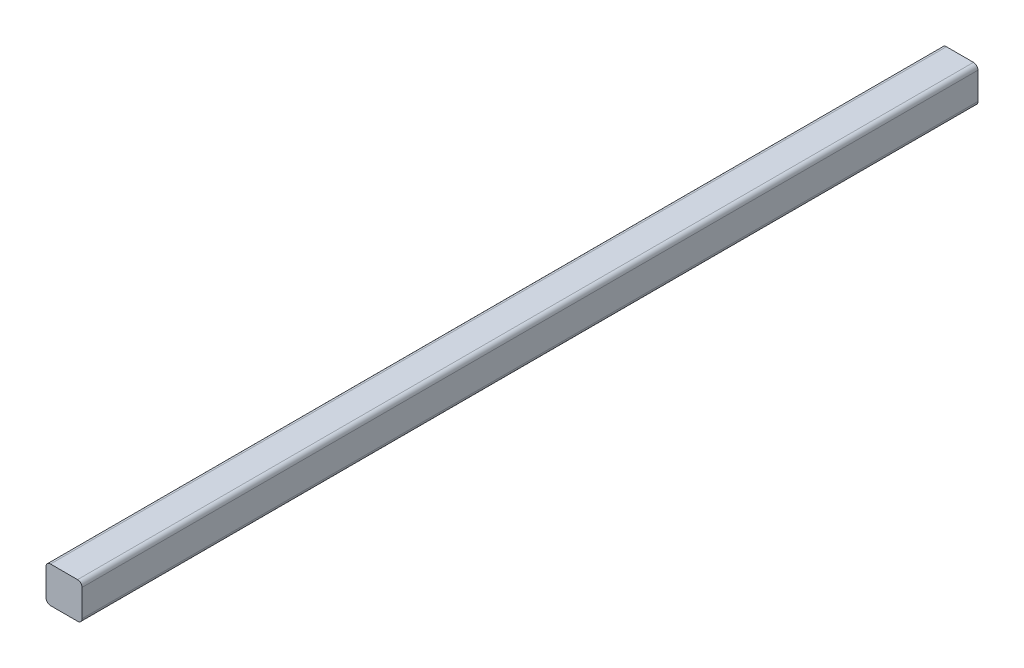
from build123d import *

# Parameters (mm, degrees)
SKETCH1_W           = 38.1
SKETCH1_H           = 38.1
BOSS_EXTRUDE1_DEPTH = 946.658829
FILLET1_R           = 4.7625


with BuildPart() as part:
    # Sketch1 → Boss-Extrude1 (new body)
    with BuildSketch(Plane.XY):
        with Locations((-566.882187925, 496.244664652)):
            Rectangle(SKETCH1_W, SKETCH1_H)
    extrude(amount=-BOSS_EXTRUDE1_DEPTH)

    # Fillet1
    fillet1_edges = [part.edges().sort_by_distance(p)[0] for p in [
        (-547.832187925, 477.194664652, -473.3294145),
        (-547.832187925, 515.294664652, -473.3294145),
        (-585.932187925, 515.294664652, -473.3294145),
        (-585.932187925, 477.194664652, -473.3294145),
    ]]
    fillet(fillet1_edges, radius=FILLET1_R)


solid = part.part
